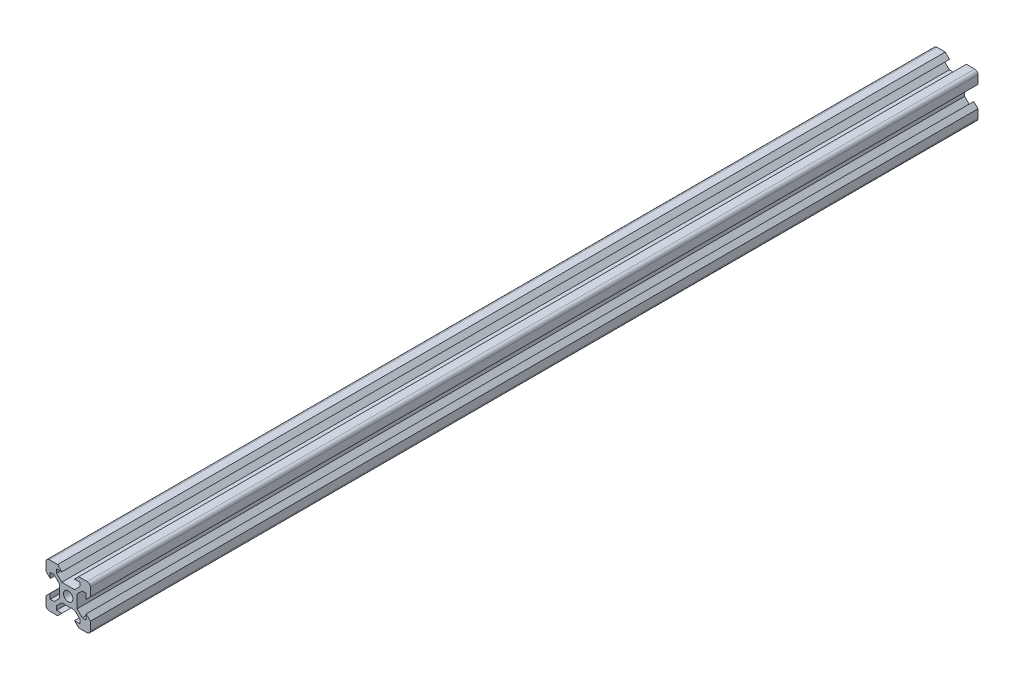
from build123d import *

# Parameters (mm, degrees)
SKETCH1_R           = 2.125
BOSS_EXTRUDE1_DEPTH = 400


with BuildPart() as part:
    # Sketch1 → Boss-Extrude1 (new body)
    with BuildSketch(Plane.XY):
        with BuildLine():
            Line((8.1, 5.225), (8.1, 2.85))
            Line((8.1, 2.85), (10, 4.75))
            Line((10, 4.75), (10, 8.5))
            ThreePointArc((10, 8.5), (9.560660172, 9.560660172), (8.5, 10))
            Line((8.5, 10), (4.75, 10))
            Line((4.75, 10), (2.85, 8.1))
            Line((2.85, 8.1), (5.225, 8.1))
            Line((5.225, 8.1), (5.225, 6.325))
            Line((5.225, 6.325), (2.9, 4))
            Line((2.9, 4), (-2.9, 4))
            Line((-2.9, 4), (-5.225, 6.325))
            Line((-5.225, 6.325), (-5.225, 8.1))
            Line((-5.225, 8.1), (-2.85, 8.1))
            Line((-2.85, 8.1), (-4.75, 10))
            Line((-4.75, 10), (-8.5, 10))
            ThreePointArc((-8.5, 10), (-9.560660172, 9.560660172), (-10, 8.5))
            Line((-10, 8.5), (-10, 4.75))
            Line((-10, 4.75), (-8.1, 2.85))
            Line((-8.1, 2.85), (-8.1, 5.225))
            Line((-8.1, 5.225), (-6.325, 5.225))
            Line((-6.325, 5.225), (-4, 2.9))
            Line((-4, 2.9), (-4, -2.9))
            Line((-4, -2.9), (-6.325, -5.225))
            Line((-6.325, -5.225), (-8.1, -5.225))
            Line((-8.1, -5.225), (-8.1, -2.85))
            Line((-8.1, -2.85), (-10, -4.75))
            Line((-10, -4.75), (-10, -8.5))
            ThreePointArc((-10, -8.5), (-9.560660172, -9.560660172), (-8.5, -10))
            Line((-8.5, -10), (-4.75, -10))
            Line((-4.75, -10), (-2.85, -8.1))
            Line((-2.85, -8.1), (-5.225, -8.1))
            Line((-5.225, -8.1), (-5.225, -6.325))
            Line((-5.225, -6.325), (-2.9, -4))
            Line((-2.9, -4), (2.9, -4))
            Line((2.9, -4), (5.225, -6.325))
            Line((5.225, -6.325), (5.225, -8.1))
            Line((5.225, -8.1), (2.85, -8.1))
            Line((2.85, -8.1), (4.75, -10))
            Line((4.75, -10), (8.5, -10))
            ThreePointArc((8.5, -10), (9.560660172, -9.560660172), (10, -8.5))
            Line((10, -8.5), (10, -4.75))
            Line((10, -4.75), (8.1, -2.85))
            Line((8.1, -2.85), (8.1, -5.225))
            Line((8.1, -5.225), (6.325, -5.225))
            Line((6.325, -5.225), (4, -2.9))
            Line((4, -2.9), (4, 2.9))
            Line((4, 2.9), (6.325, 5.225))
            Line((6.325, 5.225), (8.1, 5.225))
        make_face()
        Circle(SKETCH1_R, mode=Mode.SUBTRACT)
    extrude(amount=BOSS_EXTRUDE1_DEPTH)


solid = part.part
